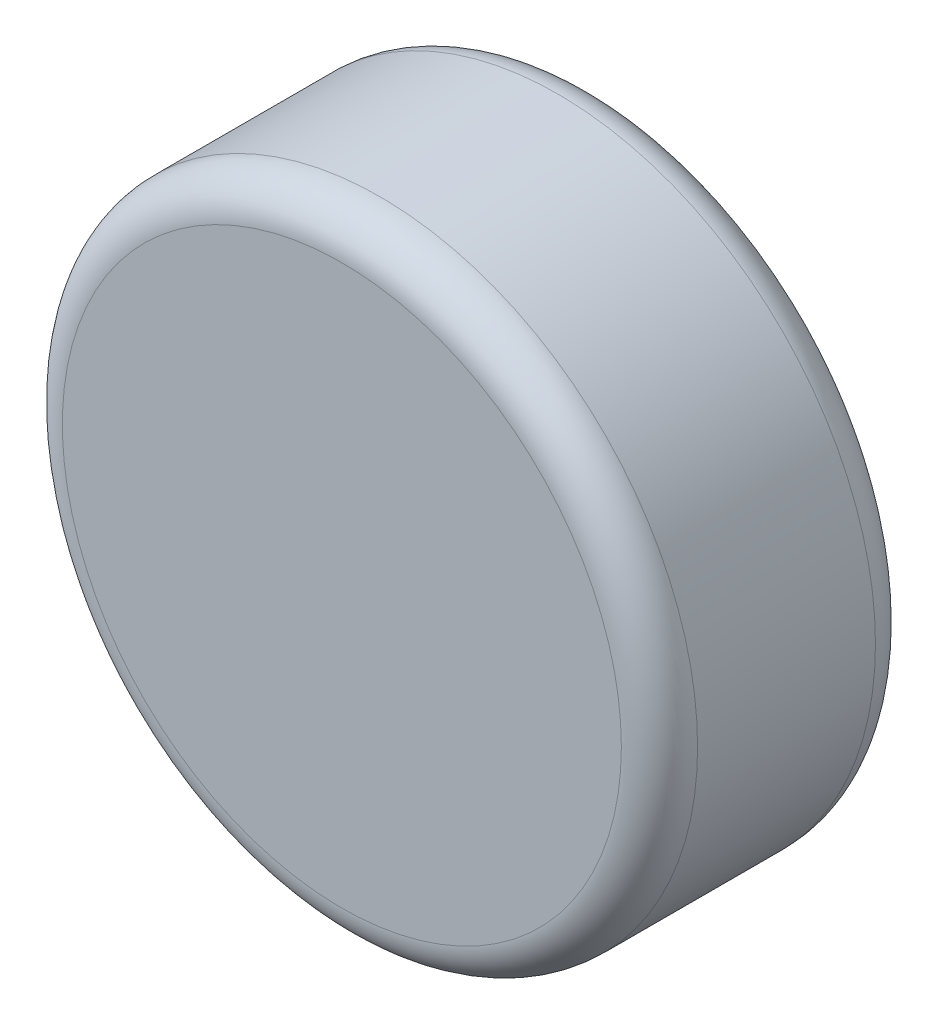
from build123d import *

# Parameters (mm, degrees)
SKETCH_1_R      = 2.5
EXTRUDE_1_DEPTH = 2
FILLET_1_R      = 0.3


with BuildPart() as part:
    # 草图1 → 凸台-拉伸1 (new body)
    with BuildSketch(Plane.XY):
        Circle(SKETCH_1_R)
    extrude(amount=EXTRUDE_1_DEPTH)

    # 圆角1
    fillet_1_edges = [part.edges().sort_by_distance(p)[0] for p in [
        (-2.5, 0, 0),
        (-2.5, 0, 2),
    ]]
    fillet(fillet_1_edges, radius=FILLET_1_R)


solid = part.part
